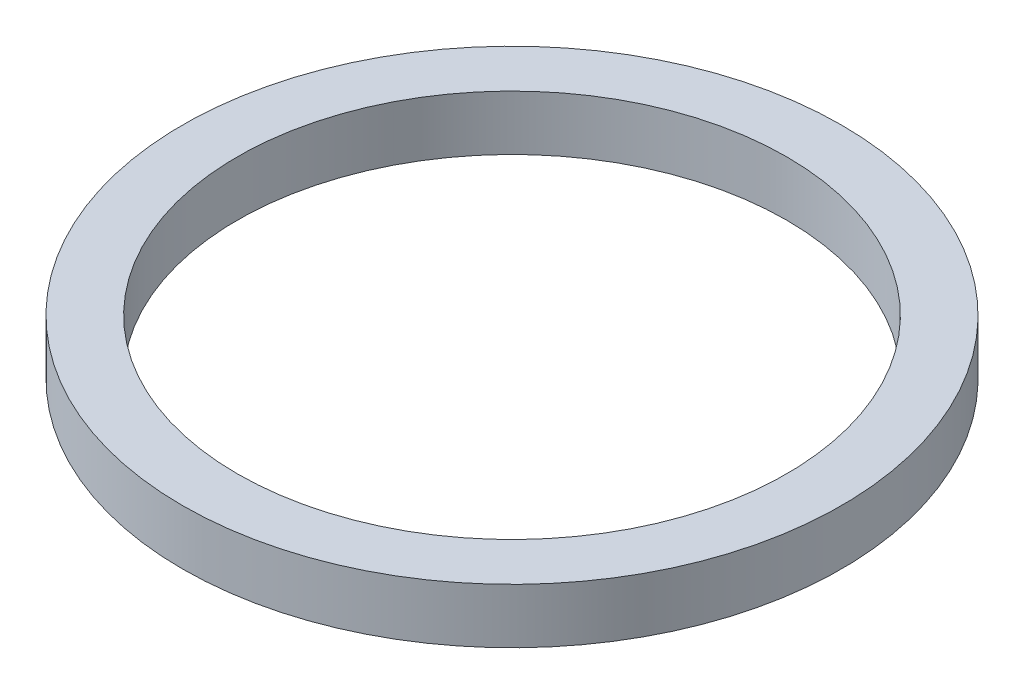
from build123d import *

# Parameters (mm, degrees)
SKETCH1_R           = 3
SKETCH1_R_2         = 2.5
BOSS_EXTRUDE1_DEPTH = 0.5


with BuildPart() as part:
    # Sketch1 → Boss-Extrude1 (new body)
    with BuildSketch(Plane(origin=(0, 0, 0), x_dir=(1, 0, 0), z_dir=(0, 1, 0))):
        Circle(SKETCH1_R)
        Circle(SKETCH1_R_2, mode=Mode.SUBTRACT)
    extrude(amount=BOSS_EXTRUDE1_DEPTH)


solid = part.part
